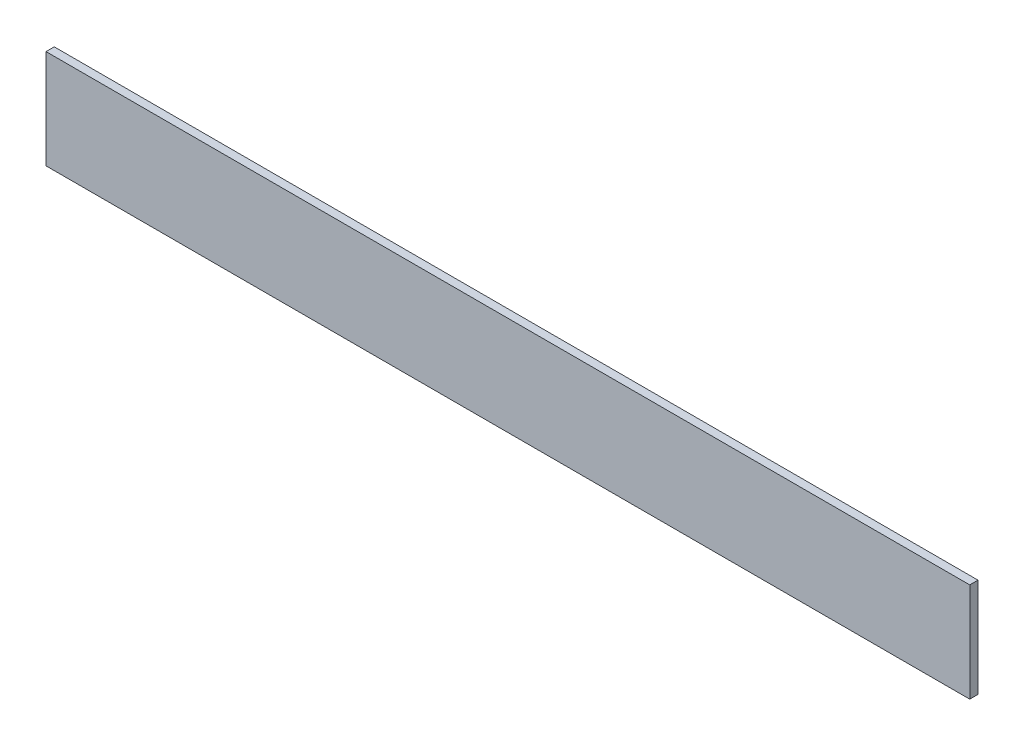
from build123d import *

# Parameters (mm, degrees)
SKETCH1_W           = 6.35
SKETCH1_H           = 76.2
BOSS_EXTRUDE1_DEPTH = 711.2


with BuildPart() as part:
    # Sketch1 → Boss-Extrude1 (new body)
    with BuildSketch(Plane(origin=(0, 0, 0), x_dir=(0, 0, -1), z_dir=(1, 0, 0))):
        Rectangle(SKETCH1_W, SKETCH1_H)
    extrude(amount=BOSS_EXTRUDE1_DEPTH)


solid = part.part
